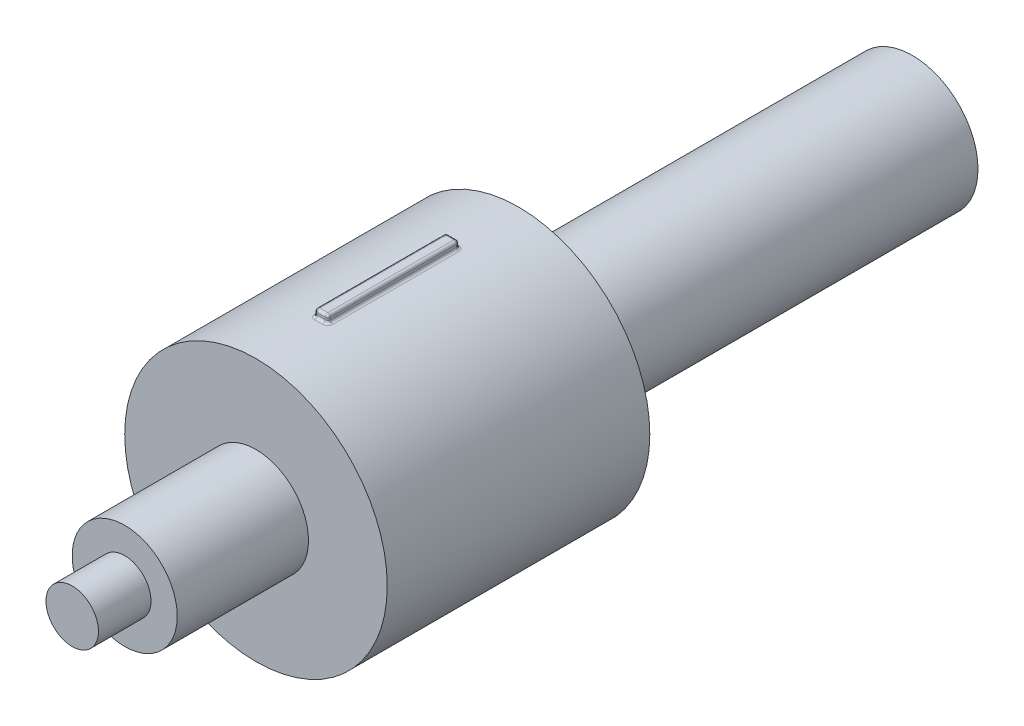
from build123d import *

# Parameters (mm, degrees)
SKETCH1_R           = 5
BOSS_EXTRUDE1_DEPTH = 30
SKETCH2_R           = 10
BOSS_EXTRUDE2_DEPTH = 20
SKETCH3_R           = 4
BOSS_EXTRUDE3_DEPTH = 10
SKETCH4_R           = 2
BOSS_EXTRUDE4_DEPTH = 4
BOSS_EXTRUDE5_START = -5
BOSS_EXTRUDE5_DEPTH = 10
FILLET1_R           = 0.2


with BuildPart() as part:
    # Sketch1 → Boss-Extrude1 (new body)
    with BuildSketch(Plane.XY):
        Circle(SKETCH1_R)
    extrude(amount=BOSS_EXTRUDE1_DEPTH)

    # Sketch2 → Boss-Extrude2 (add)
    with BuildSketch(Plane.XY.offset(30)):
        Circle(SKETCH2_R)
    extrude(amount=BOSS_EXTRUDE2_DEPTH)

    # Sketch3 → Boss-Extrude3 (add)
    with BuildSketch(Plane.XY.offset(50)):
        Circle(SKETCH3_R)
    extrude(amount=BOSS_EXTRUDE3_DEPTH)

    # Sketch4 → Boss-Extrude4 (add)
    with BuildSketch(Plane.XY.offset(60)):
        Circle(SKETCH4_R)
    extrude(amount=BOSS_EXTRUDE4_DEPTH)

    # Sketch5 → Boss-Extrude5 (add)
    with BuildSketch(Plane(origin=(0, 0, 30), x_dir=(-1, 0, 0), z_dir=(0, 0, -1)).offset(BOSS_EXTRUDE5_START)):
        with BuildLine():
            Line((-0.464729596, 10.560180083), (0.535270404, 10.560180083))
            Line((0.535270404, 10.560180083), (0.535270404, 9.960180083))
            ThreePointArc((0.535270404, 9.960180083), (0.035314802, 9.97449019), (-0.464729596, 9.963720595))
            Line((-0.464729596, 9.963720595), (-0.464729596, 10.560180083))
        make_face()
    extrude(amount=-BOSS_EXTRUDE5_DEPTH)

    # Fillet1
    fillet1_edges = [part.edges().sort_by_distance(p)[0] for p in [
        (-0.035314575, 9.999937644, 35),
        (-0.535270404, 9.985664004, 40),
        (0.464729596, 9.989195483, 40),
        (-0.035314575, 9.999937644, 45),
        (0.464729596, 10.274687783, 45),
        (-0.535270404, 10.272922043, 45),
        (-0.535270404, 10.560180083, 40),
        (-0.035270404, 10.560180083, 45),
        (0.464729596, 10.560180083, 40),
        (-0.535270404, 10.272922043, 35),
        (-0.035270404, 10.560180083, 35),
        (0.464729596, 10.274687783, 35),
    ]]
    fillet(fillet1_edges, radius=FILLET1_R)


solid = part.part
